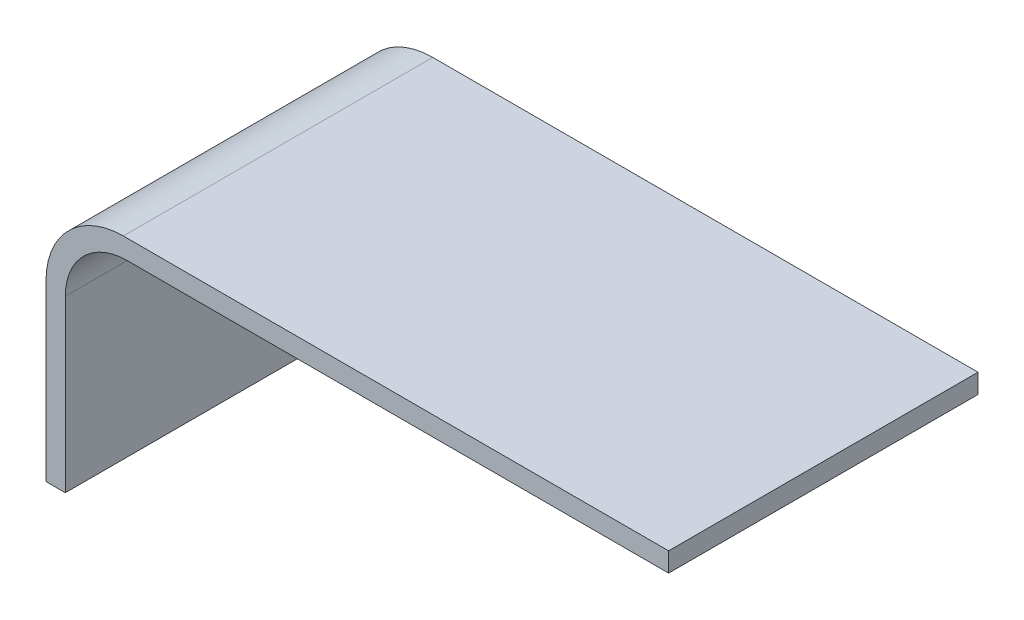
from build123d import *

# Parameters (mm, degrees)
BOSS_EXTRUDE1_DEPTH = 101.6


with BuildPart() as part:
    # Sketch1 → Boss-Extrude1 (new body)
    with BuildSketch(Plane.XY):
        with BuildLine():
            Line((25.4, 0), (204.47, 0))
            Line((204.47, 0), (204.47, -6.35))
            Line((204.47, -6.35), (26.67, -6.35))
            ThreePointArc((26.67, -6.35), (12.301590206, -12.301590206), (6.35, -26.67))
            Line((6.35, -26.67), (6.35, -82.55))
            Line((6.35, -82.55), (0, -82.55))
            Line((0, -82.55), (0, -25.4))
            ThreePointArc((0, -25.4), (7.439487758, -7.439487758), (25.4, 0))
        make_face()
    extrude(amount=BOSS_EXTRUDE1_DEPTH)


solid = part.part
